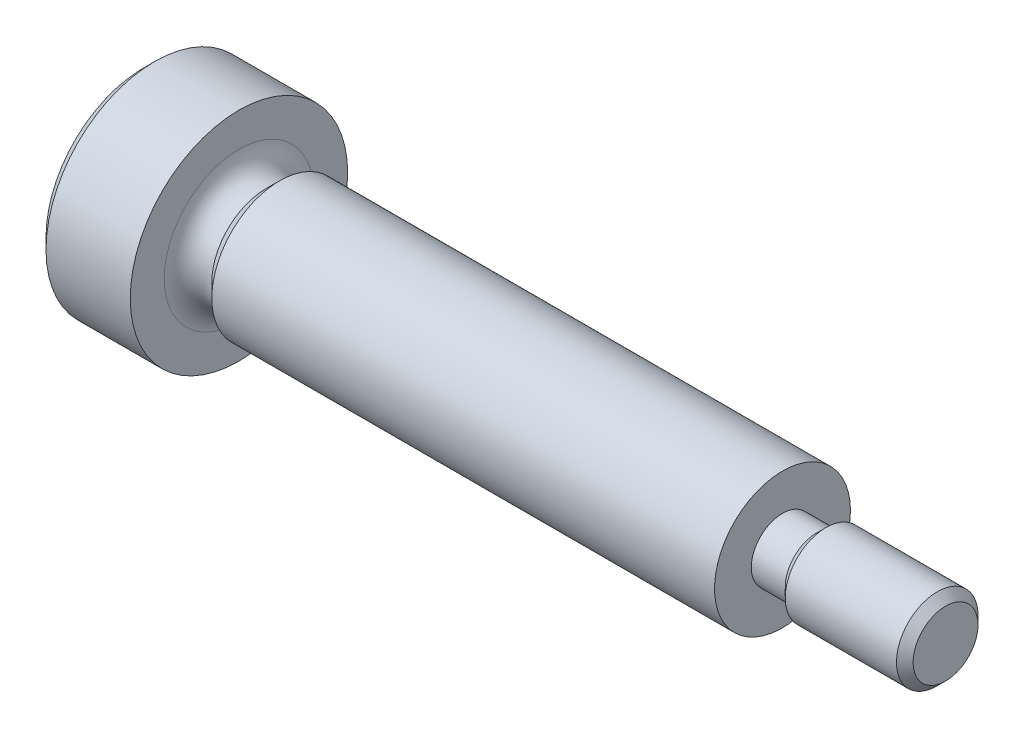
from build123d import *

# Parameters (mm, degrees)
SKETCH2_R           = 2
BOSS_EXTRUDE1_DEPTH = 0.5
BOSS_EXTRUDE1_TAPER = -45
SKETCH3_R           = 2.5
BOSS_EXTRUDE2_DEPTH = 18.501
SKETCH4_R           = 1.15
BOSS_EXTRUDE3_DEPTH = 1.25
SKETCH5_R           = 1.15
BOSS_EXTRUDE4_DEPTH = 0.35
BOSS_EXTRUDE4_TAPER = -44.999999995
SKETCH6_R           = 1.5
BOSS_EXTRUDE5_DEPTH = 4.0935
SKETCH7_R           = 1.5
BOSS_EXTRUDE6_DEPTH = 0.3065
BOSS_EXTRUDE6_TAPER = 45
CUT_EXTRUDE1_DEPTH  = 1.6
CHAMFER1_SIZE       = 0.4


with BuildPart() as part:
    # Sketch1 → Revolve1 (revolve)
    with BuildSketch(Plane(origin=(0, 0, 0), x_dir=(-1, 0, 0), z_dir=(0, 0, -1))):
        with BuildLine():
            Line((-0.999, 2), (-0.999, 0))
            Line((-0.999, 0), (3.5, 0))
            Line((3.5, 0), (3.5, 4))
            Line((3.5, 4), (0, 4))
            Line((0, 4), (0, 2.75))
            ThreePointArc((0, 2.75), (-0.325180465, 2.142806379), (-0.999, 2))
        make_face()
    revolve(axis=Axis((0.999, 0, 0), (-1, 0, 0)))

    # Sketch2 → Boss-Extrude1 (add)
    with BuildSketch(Plane(origin=(0.999, 0, 0), x_dir=(0, 0, -1), z_dir=(1, 0, 0))):
        Circle(SKETCH2_R)
    extrude(amount=BOSS_EXTRUDE1_DEPTH, taper=BOSS_EXTRUDE1_TAPER)

    # Sketch3 → Boss-Extrude2 (add)
    with BuildSketch(Plane(origin=(1.499, 0, 0), x_dir=(0, 0, -1), z_dir=(1, 0, 0))):
        Circle(SKETCH3_R)
    extrude(amount=BOSS_EXTRUDE2_DEPTH)

    # Sketch4 → Boss-Extrude3 (add)
    with BuildSketch(Plane(origin=(20, 0, 0), x_dir=(0, 0, -1), z_dir=(1, 0, 0))):
        Circle(SKETCH4_R)
    extrude(amount=BOSS_EXTRUDE3_DEPTH)

    # Sketch5 → Boss-Extrude4 (add)
    with BuildSketch(Plane(origin=(21.25, 0, 0), x_dir=(0, 0, -1), z_dir=(1, 0, 0))):
        Circle(SKETCH5_R)
    extrude(amount=BOSS_EXTRUDE4_DEPTH, taper=BOSS_EXTRUDE4_TAPER)

    # Sketch6 → Boss-Extrude5 (add)
    with BuildSketch(Plane(origin=(21.6, 0, 0), x_dir=(0, 0, -1), z_dir=(1, 0, 0))):
        Circle(SKETCH6_R)
    extrude(amount=BOSS_EXTRUDE5_DEPTH)

    # Sketch7 → Boss-Extrude6 (add)
    with BuildSketch(Plane(origin=(25.6935, 0, 0), x_dir=(0, 0, -1), z_dir=(1, 0, 0))):
        Circle(SKETCH7_R)
    extrude(amount=BOSS_EXTRUDE6_DEPTH, taper=BOSS_EXTRUDE6_TAPER)

    # Sketch8 → Cut-Extrude1 (cut)
    with BuildSketch(Plane.ZY.offset(3.5)):
        Polygon((0, 1.443375673), (-1.25, 0.721687836), (-1.25, -0.721687836), (0, -1.443375673), (1.25, -0.721687836), (1.25, 0.721687836), align=None)
    extrude(amount=-CUT_EXTRUDE1_DEPTH, mode=Mode.SUBTRACT)

    # Sketch9 → Cut-Revolve1 (revolve, cut)
    with BuildSketch(Plane.XY):
        Polygon((-1.9, 1.25), (-1.9, 0), (-1.178312164, 0), align=None)
    revolve(axis=Axis((-1.9, 0, 0), (1, 0, 0)), mode=Mode.SUBTRACT)

    # Chamfer1
    chamfer1_edges = [part.edges().sort_by_distance(p)[0] for p in [
        (-3.5, -4, 0),
    ]]
    chamfer(chamfer1_edges, length=CHAMFER1_SIZE)


solid = part.part
